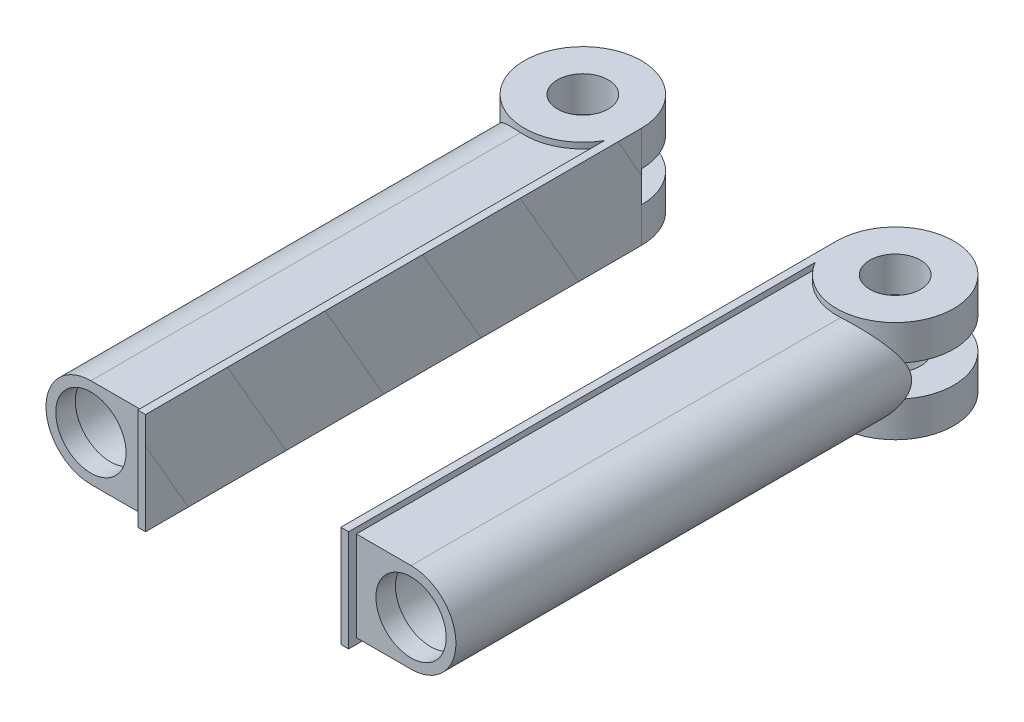
from build123d import *

# Parameters (mm, degrees)
SKETCH1_R           = 30
BOSS_EXTRUDE1_DEPTH = 26
BOSS_EXTRUDE2_DEPTH = 250
SKETCH4_R           = 13
CUT_EXTRUDE2_DEPTH  = 26
SKETCH1_2_R         = 30
CUT_EXTRUDE3_DEPTH  = 8
CUT_EXTRUDE4_START  = 8
SKETCH1_3_R         = 30
CUT_EXTRUDE4_DEPTH  = 8
SKETCH5_R           = 19
CUT_EXTRUDE5_DEPTH  = 210
SKETCH7_W           = 4
SKETCH7_H           = 4
BOSS_EXTRUDE4_DEPTH = 26
SKETCH9_R           = 19
SKETCH9_R_2         = 18
BOSS_EXTRUDE5_DEPTH = 10


with BuildPart() as part:
    # Sketch1 → Boss-Extrude1 (new, symmetric)
    with BuildSketch(Plane(origin=(0, 0, 0), x_dir=(1, 0, 0), z_dir=(0, 1, 0))):
        Circle(SKETCH1_R)
    extrude(amount=BOSS_EXTRUDE1_DEPTH, both=True)

    # Sketch3 → Boss-Extrude2 (add)
    with BuildSketch(Plane.XY):
        with BuildLine():
            Line((26, 26), (26, 23))
            Line((26, 23), (-2, 23))
            ThreePointArc((-2, 23), (-25, 0), (-2, -23))
            Line((-2, -23), (26, -23))
            Line((26, -23), (26, -26))
            Line((26, -26), (30, -26))
            Line((30, -26), (30, 26))
            Line((30, 26), (26, 26))
        make_face()
    extrude(amount=BOSS_EXTRUDE2_DEPTH)

    # Sketch4 → Cut-Extrude2 (cut, symmetric)
    with BuildSketch(Plane(origin=(0, 0, 0), x_dir=(1, 0, 0), z_dir=(0, 1, 0))):
        Circle(SKETCH4_R)
    extrude(amount=CUT_EXTRUDE2_DEPTH, both=True, mode=Mode.SUBTRACT)

    # Sketch1_2 → Cut-Extrude3 (cut)
    with BuildSketch(Plane(origin=(0, 0, 0), x_dir=(1, 0, 0), z_dir=(0, 1, 0))):
        Circle(SKETCH1_2_R)
    extrude(amount=-CUT_EXTRUDE3_DEPTH, mode=Mode.SUBTRACT)

    # Sketch1_3 → Cut-Extrude4 (cut)
    with BuildSketch(Plane(origin=(0, 0, 0), x_dir=(1, 0, 0), z_dir=(0, 1, 0)).offset(CUT_EXTRUDE4_START)):
        Circle(SKETCH1_3_R)
    extrude(amount=-CUT_EXTRUDE4_DEPTH, mode=Mode.SUBTRACT)

    # Sketch5 → Cut-Extrude5 (cut)
    with BuildSketch(Plane.XY.offset(250)):
        with Locations((-2, 0)):
            Circle(SKETCH5_R)
    extrude(amount=-CUT_EXTRUDE5_DEPTH, mode=Mode.SUBTRACT)

    # Sketch7 → Boss-Extrude4 (add, symmetric)
    with BuildSketch(Plane(origin=(0, 0, 0), x_dir=(1, 0, 0), z_dir=(0, 1, 0))):
        with Locations((28, -252)):
            Rectangle(SKETCH7_W, SKETCH7_H)
    extrude(amount=BOSS_EXTRUDE4_DEPTH, both=True)

    # Sketch9 → Boss-Extrude5 (add)
    with BuildSketch(Plane.XY.offset(250)):
        with Locations((-2, 0)):
            Circle(SKETCH9_R)
        with Locations((-2, 0)):
            Circle(SKETCH9_R_2, mode=Mode.SUBTRACT)
    extrude(amount=-BOSS_EXTRUDE5_DEPTH)


with BuildPart() as body_2:
    # Mirror2: mirrored copy
    add(part.part.mirror(Plane(origin=(80, 0, 0), x_dir=(0, 0, 1), z_dir=(1, 0, 0))))


solid = Compound([part.part, body_2.part])
